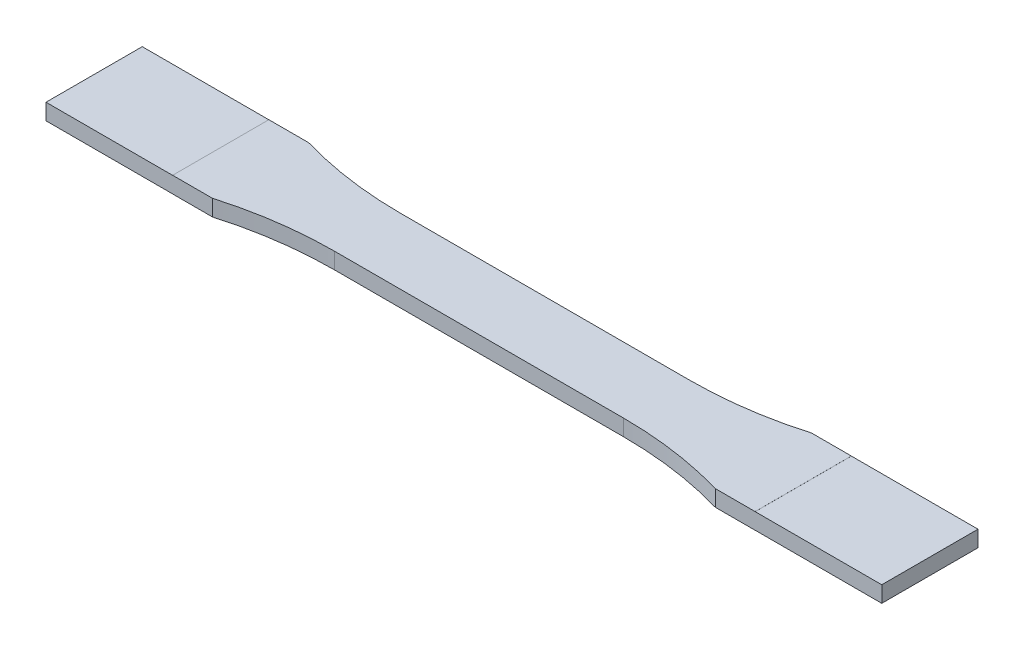
from build123d import *

# Parameters (mm, degrees)
CROQUIS1_W              = 57
CROQUIS1_H              = 13
SALIENTE_EXTRUIR1_DEPTH = 1.6
CROQUIS2_W              = 25
CROQUIS2_H              = 19
CORTAR_EXTRUIR1_DEPTH   = 0.01


with BuildPart() as part:
    # Croquis1 → Saliente-Extruir1 (new body, symmetric)
    with BuildSketch(Plane(origin=(0, 0, 0), x_dir=(1, 0, 0), z_dir=(0, 1, 0))):
        with BuildLine():
            Line((-82.5, -9.5), (-49.642374512, -9.5))
            ThreePointArc((-49.642374512, -9.5), (-39.177078252, -7.253737634), (-28.5, -6.5))
            Line((-28.5, -6.5), (-28.5, 6.5))
            ThreePointArc((-28.5, 6.5), (-39.177078252, 7.253737634), (-49.642374512, 9.5))
            Line((-49.642374512, 9.5), (-82.5, 9.5))
            Line((-82.5, 9.5), (-82.5, -9.5))
        make_face()
        with BuildLine():
            Line((49.642374512, -9.5), (82.5, -9.5))
            Line((82.5, -9.5), (82.5, 9.5))
            Line((82.5, 9.5), (49.642374512, 9.5))
            ThreePointArc((49.642374512, 9.5), (39.177078252, 7.253737634), (28.5, 6.5))
            Line((28.5, 6.5), (28.5, -6.5))
            ThreePointArc((28.5, -6.5), (39.177078252, -7.253737634), (49.642374512, -9.5))
        make_face()
        Rectangle(CROQUIS1_W, CROQUIS1_H)
    extrude(amount=SALIENTE_EXTRUIR1_DEPTH, both=True)

    # Croquis2 → Cortar-Extruir1 (cut)
    with BuildSketch(Plane(origin=(0, 1.6, 0), x_dir=(1, 0, 0), z_dir=(0, 1, 0))):
        with Locations((-70, 0)):
            Rectangle(CROQUIS2_W, CROQUIS2_H)
        with Locations((70, 0)):
            Rectangle(CROQUIS2_W, CROQUIS2_H)
    cortar_extruir1 = extrude(amount=-CORTAR_EXTRUIR1_DEPTH, mode=Mode.SUBTRACT)

    # Simetría1: Cortar-Extruir1 across plane
    add(cortar_extruir1.mirror(Plane.ZX), mode=Mode.SUBTRACT)


solid = part.part
